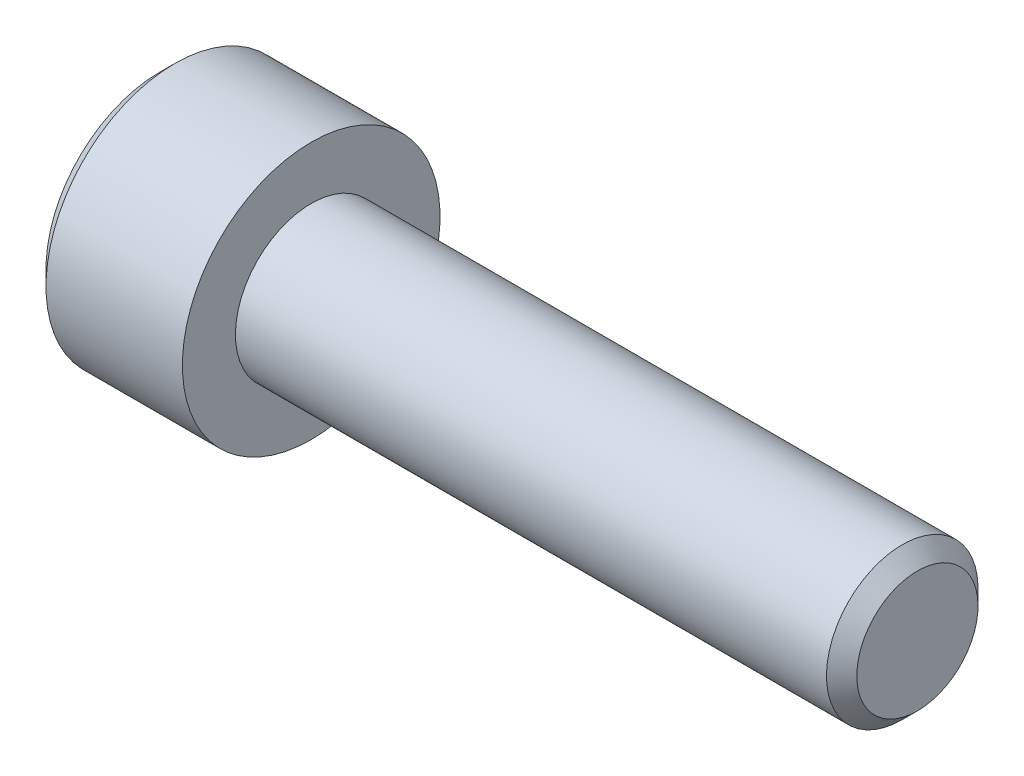
from build123d import *

# Parameters (mm, degrees)
CHAMFER1_SIZE      = 0.5
CUT_EXTRUDE1_DEPTH = 2.5


with BuildPart() as part:
    # Sketch1 → Revolve1 (revolve)
    with BuildSketch(Plane.XY):
        Polygon((-5, 0), (-5, 3.75), (-4.5, 4.25), (0, 4.25), (0, 2.5), (20, 2.5), (20, 0), align=None)
    revolve(axis=Axis((20, 0, 0), (-1, 0, 0)))

    # Chamfer1
    chamfer1_edges = [part.edges().sort_by_distance(p)[0] for p in [
        (20, -2.5, 0),
    ]]
    chamfer(chamfer1_edges, length=CHAMFER1_SIZE)

    # Sketch2 → Cut-Revolve1 (revolve, cut)
    with BuildSketch(Plane.XY):
        Polygon((-5, 0), (-5, 2), (-2.5, 2), (-1.964101615, 0), align=None)
    revolve(axis=Axis((-1.964101615, 0, 0), (-1, 0, 0)), mode=Mode.SUBTRACT)

    # Sketch3 → Cut-Extrude1 (cut)
    with BuildSketch(Plane(origin=(-5, 0, 0), x_dir=(0, 0, -1), z_dir=(1, 0, 0))):
        Polygon((-2, 1.154700538), (-2, -1.154700538), (0, -2.309401077), (2, -1.154700538), (2, 1.154700538), (0, 2.309401077), align=None)
    extrude(amount=CUT_EXTRUDE1_DEPTH, mode=Mode.SUBTRACT)


solid = part.part
